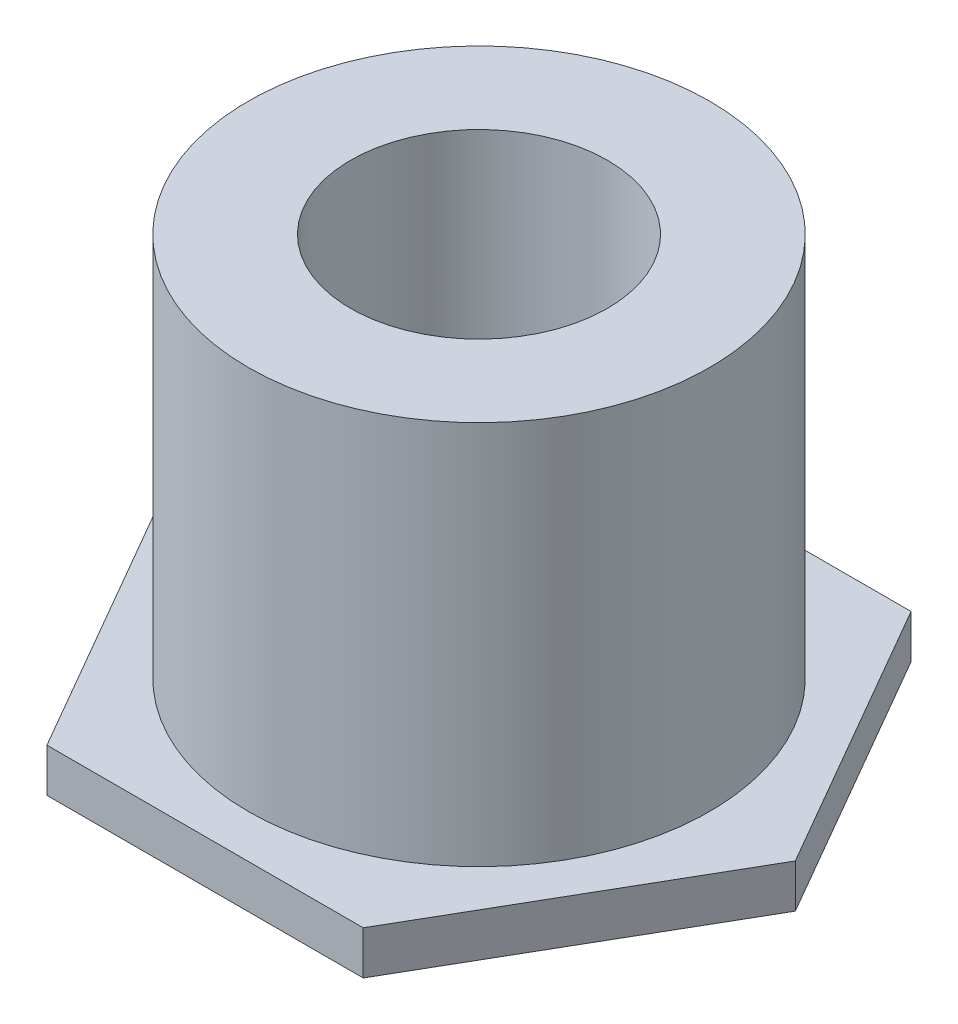
from build123d import *

# Parameters (mm, degrees)
BOSS_EXTRUDE1_DEPTH = 0.508
SKETCH2_R           = 2.695
SKETCH2_R_2         = 1.5
BOSS_EXTRUDE2_DEPTH = 5


with BuildPart() as part:
    # Sketch1 → Boss-Extrude1 (new body)
    with BuildSketch(Plane(origin=(0, 0, 0), x_dir=(1, 0, 0), z_dir=(0, 1, 0))):
        Polygon((1.847520861, -3.2), (3.695041723, 0), (1.847520861, 3.2), (-1.847520861, 3.2), (-3.695041723, 0), (-1.847520861, -3.2), align=None)
    extrude(amount=BOSS_EXTRUDE1_DEPTH)

    # Sketch2 → Boss-Extrude2 (add)
    with BuildSketch(Plane.XZ):
        Circle(SKETCH2_R)
        Circle(SKETCH2_R_2, mode=Mode.SUBTRACT)
    extrude(amount=-BOSS_EXTRUDE2_DEPTH)


solid = part.part
